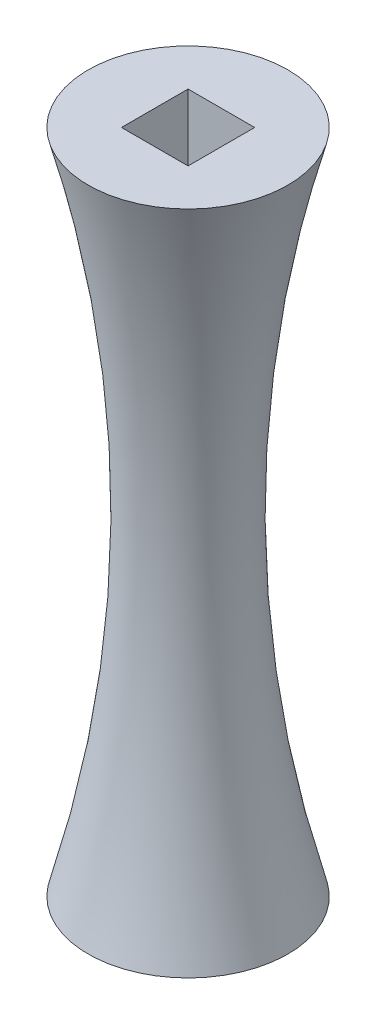
from build123d import *

# Parameters (mm, degrees)
SKETCH_1_R          = 7.5
EXTRUDE_1_DEPTH     = 50
SKETCH_2_W          = 5
SKETCH_2_H          = 5
CUT_EXTRUDE_1_DEPTH = 10
SKETCH_3_W          = 5
SKETCH_3_H          = 5
CUT_EXTRUDE_2_DEPTH = 10


with BuildPart() as part:
    # 草图1 → 凸台-拉伸1 (new body)
    with BuildSketch(Plane(origin=(0, 0, 0), x_dir=(1, 0, 0), z_dir=(0, 1, 0))):
        Circle(SKETCH_1_R)
    extrude(amount=EXTRUDE_1_DEPTH)

    # 草图2 → 切除-拉伸1 (cut)
    with BuildSketch(Plane(origin=(0, 50, 0), x_dir=(1, 0, 0), z_dir=(0, 1, 0))):
        Rectangle(SKETCH_2_W, SKETCH_2_H)
    extrude(amount=-CUT_EXTRUDE_1_DEPTH, mode=Mode.SUBTRACT)

    # 草图3 → 切除-拉伸2 (cut)
    with BuildSketch(Plane.XZ):
        Rectangle(SKETCH_3_W, SKETCH_3_H)
    extrude(amount=-CUT_EXTRUDE_2_DEPTH, mode=Mode.SUBTRACT)

    # 草图4 → 切除-旋转1 (revolve, cut)
    with BuildSketch(Plane(origin=(0, 0, 0), x_dir=(0, 0, -1), z_dir=(1, 0, 0))):
        with BuildLine():
            Line((-7.5, 50), (-7.5, 0))
            ThreePointArc((-7.5, 0), (-4.092291539, 25), (-7.5, 50))
        make_face()
    revolve(axis=Axis((0, 0, 0), (0, 1, 0)), mode=Mode.SUBTRACT)


solid = part.part
